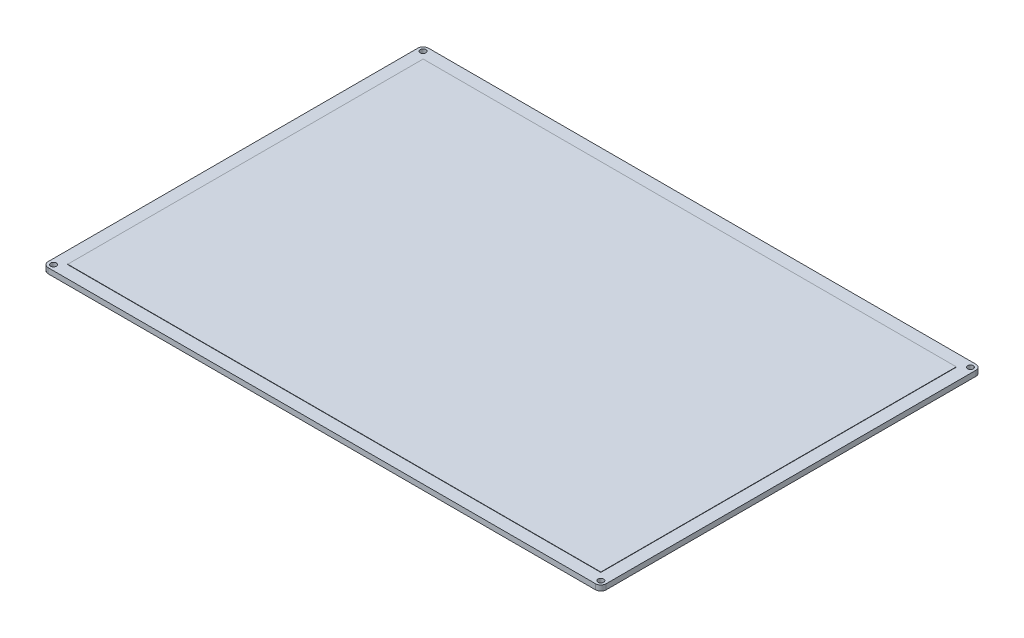
from build123d import *

# Parameters (mm, degrees)
SKETCH1_W                      = 314
SKETCH1_H                      = 214
BOSS_EXTRUDE1_DEPTH            = 3
SKETCH2_W                      = 300
SKETCH2_H                      = 200
BOSS_EXTRUDE2_DEPTH            = 0.2
F_3_2_3_2_DIAMETER_HOLE1_D     = 3.2
F_3_2_3_2_DIAMETER_HOLE1_DEPTH = 3
FILLET1_R                      = 3


with BuildPart() as part:
    # Sketch1 → Boss-Extrude1 (new body)
    with BuildSketch(Plane(origin=(0, 3, 0), x_dir=(1, 0, 0), z_dir=(0, 1, 0))):
        Rectangle(SKETCH1_W, SKETCH1_H)
    extrude(amount=-BOSS_EXTRUDE1_DEPTH)

    # Sketch2 → Boss-Extrude2 (add)
    with BuildSketch(Plane(origin=(0, 3, 0), x_dir=(-1, 0, 0), z_dir=(0, 1, 0))):
        Rectangle(SKETCH2_W, SKETCH2_H)
    extrude(amount=BOSS_EXTRUDE2_DEPTH)

    # Ø3.2 (3.2) Diameter Hole1
    with Locations(Plane(origin=(0, 3, 0), x_dir=(1, 0, 0), z_dir=(0, 1, 0))):
        with Locations((154, -104), (-154, -104), (154, 104), (-154, 104)):
            Hole(F_3_2_3_2_DIAMETER_HOLE1_D / 2, depth=F_3_2_3_2_DIAMETER_HOLE1_DEPTH)

    # Fillet1
    fillet1_edges = [part.edges().sort_by_distance(p)[0] for p in [
        (157, 1.5, 107),
        (-157, 1.5, 107),
        (-157, 1.5, -107),
        (157, 1.5, -107),
    ]]
    fillet(fillet1_edges, radius=FILLET1_R)


solid = part.part
